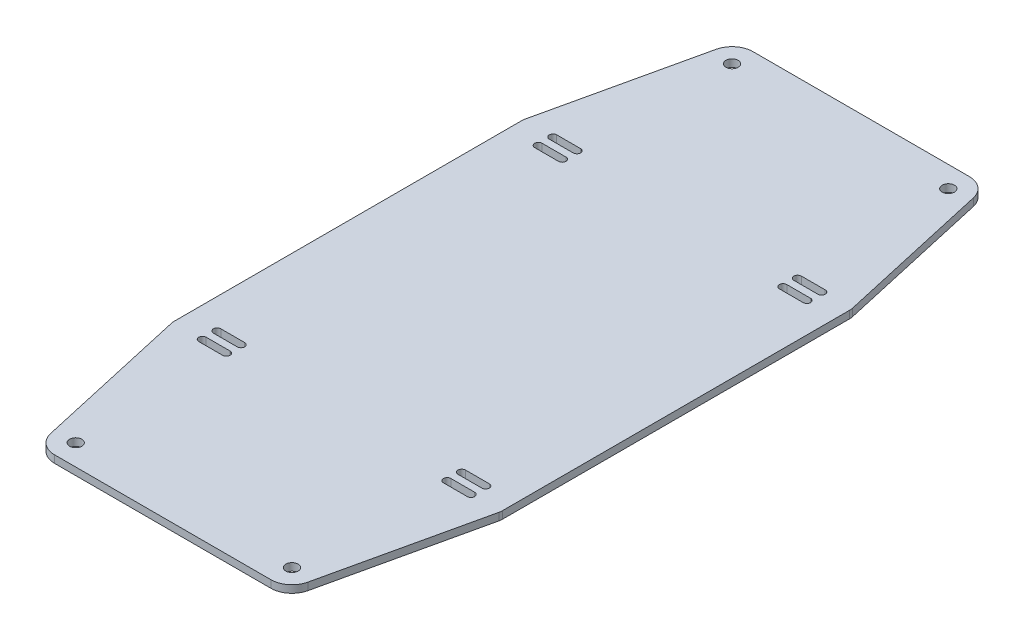
from build123d import *

# Parameters (mm, degrees)
SKETCH1_W               = 283.466794954
SKETCH1_H               = 183.213286571
BOSS_EXTRUDE1_DEPTH     = 3.175
SKETCH2_W               = 283.466794954
SKETCH2_H               = 183.213286571
CUT_EXTRUDE1_DEPTH      = 4.175
SKETCH4_W               = 139.7
SKETCH4_H               = 76.2
BOSS_EXTRUDE2_DEPTH     = 3.175
CUT_EXTRUDE2_DEPTH      = 4.175
CUT_EXTRUDE3_DEPTH      = 1
CUT_EXTRUDE3_DEPTH_BACK = 4.175
FILLET1_R               = 6.35


with BuildPart() as part:
    # Sketch1 → Boss-Extrude1 (new body)
    with BuildSketch(Plane(origin=(0, 0, 0), x_dir=(1, 0, 0), z_dir=(0, 1, 0))):
        with Locations((1.754436397, -4.260774107)):
            Rectangle(SKETCH1_W, SKETCH1_H)
    extrude(amount=BOSS_EXTRUDE1_DEPTH)

    # Sketch2 → Cut-Extrude1 (cut, through all)
    with BuildSketch(Plane(origin=(0, 3.175, 0), x_dir=(1, 0, 0), z_dir=(0, 1, 0))):
        with Locations((1.754436397, -4.260774107)):
            Rectangle(SKETCH2_W, SKETCH2_H)
        Polygon((14.612631792, -92.535731899), (1.912631792, -92.535731899), (1.912631792, -79.835731899), (1.912631792, 78.914268101), (141.612631792, 78.914268101), (141.612631792, -79.835731899), (141.612631792, -92.535731899), (128.912631792, -92.535731899), align=None, mode=Mode.SUBTRACT)
        with BuildLine():
            Line((24.772631792, 63.166268101), (14.612631792, 63.166268101))
            Line((14.612631792, 63.166268101), (14.612631792, 59.991268101))
            Line((14.612631792, 59.991268101), (24.772631792, 59.991268101))
            ThreePointArc((24.772631792, 59.991268101), (26.360131792, 61.578768101), (24.772631792, 63.166268101))
        make_face()
        with BuildLine():
            Line((14.612631792, 59.991268101), (14.612631792, 63.166268101))
            ThreePointArc((14.612631792, 63.166268101), (13.025131792, 61.578768101), (14.612631792, 59.991268101))
        make_face()
        with BuildLine():
            ThreePointArc((14.612631792, 69.389268101), (13.025131792, 67.801768101), (14.612631792, 66.214268101))
            Line((14.612631792, 66.214268101), (24.772631792, 66.214268101))
            ThreePointArc((24.772631792, 66.214268101), (26.360131792, 67.801768101), (24.772631792, 69.389268101))
            Line((24.772631792, 69.389268101), (14.612631792, 69.389268101))
        make_face()
        with BuildLine():
            Line((128.912631792, 63.166268101), (118.752631792, 63.166268101))
            ThreePointArc((118.752631792, 63.166268101), (117.165131792, 61.578768101), (118.752631792, 59.991268101))
            Line((118.752631792, 59.991268101), (128.912631792, 59.991268101))
            Line((128.912631792, 59.991268101), (128.912631792, 63.166268101))
        make_face()
        with BuildLine():
            ThreePointArc((118.752631792, 69.389268101), (117.165131792, 67.801768101), (118.752631792, 66.214268101))
            Line((118.752631792, 66.214268101), (128.912631792, 66.214268101))
            ThreePointArc((128.912631792, 66.214268101), (130.500131792, 67.801768101), (128.912631792, 69.389268101))
            Line((128.912631792, 69.389268101), (118.752631792, 69.389268101))
        make_face()
        with BuildLine():
            ThreePointArc((128.912631792, -83.010731899), (130.500131792, -81.423231899), (128.912631792, -79.835731899))
            Line((128.912631792, -79.835731899), (118.752631792, -79.835731899))
            ThreePointArc((118.752631792, -79.835731899), (117.165131792, -81.423231899), (118.752631792, -83.010731899))
            Line((118.752631792, -83.010731899), (128.912631792, -83.010731899))
        make_face()
        with BuildLine():
            ThreePointArc((128.912631792, -76.787731899), (130.500131792, -75.200231899), (128.912631792, -73.612731899))
            Line((128.912631792, -73.612731899), (128.912631792, -76.787731899))
        make_face()
        with BuildLine():
            Line((128.912631792, -76.787731899), (128.912631792, -73.612731899))
            Line((128.912631792, -73.612731899), (118.752631792, -73.612731899))
            ThreePointArc((118.752631792, -73.612731899), (117.165131792, -75.200231899), (118.752631792, -76.787731899))
            Line((118.752631792, -76.787731899), (128.912631792, -76.787731899))
        make_face()
        with BuildLine():
            ThreePointArc((128.912631792, 59.991268101), (130.500131792, 61.578768101), (128.912631792, 63.166268101))
            Line((128.912631792, 63.166268101), (128.912631792, 59.991268101))
        make_face()
        with BuildLine():
            Line((24.772631792, -79.835731899), (14.612631792, -79.835731899))
            ThreePointArc((14.612631792, -79.835731899), (13.025131792, -81.423231899), (14.612631792, -83.010731899))
            Line((14.612631792, -83.010731899), (24.772631792, -83.010731899))
            ThreePointArc((24.772631792, -83.010731899), (26.360131792, -81.423231899), (24.772631792, -79.835731899))
        make_face()
        with BuildLine():
            Line((24.772631792, -73.612731899), (14.612631792, -73.612731899))
            Line((14.612631792, -73.612731899), (14.612631792, -76.787731899))
            Line((14.612631792, -76.787731899), (24.772631792, -76.787731899))
            ThreePointArc((24.772631792, -76.787731899), (26.360131792, -75.200231899), (24.772631792, -73.612731899))
        make_face()
        with BuildLine():
            Line((14.612631792, -76.787731899), (14.612631792, -73.612731899))
            ThreePointArc((14.612631792, -73.612731899), (13.025131792, -75.200231899), (14.612631792, -76.787731899))
        make_face()
    extrude(amount=-CUT_EXTRUDE1_DEPTH, mode=Mode.SUBTRACT)

    # Sketch4 → Boss-Extrude2 (add)
    with BuildSketch(Plane(origin=(0, 3.175, 0), x_dir=(1, 0, 0), z_dir=(0, 1, 0))):
        with Locations((71.762631792, 117.014268101)):
            Rectangle(SKETCH4_W, SKETCH4_H)
        with Locations((71.762631792, -130.635731899)):
            Rectangle(SKETCH4_W, SKETCH4_H)
    extrude(amount=-BOSS_EXTRUDE2_DEPTH)

    # Sketch3 → Cut-Extrude2 (cut, through all)
    with BuildSketch(Plane(origin=(0, 3.175, 0), x_dir=(1, 0, 0), z_dir=(0, 1, 0))):
        with BuildLine():
            ThreePointArc((28.325131792, 132.889268101), (23.886654161, 134.727745733), (25.725131792, 130.289268101))
            Line((25.725131792, 130.289268101), (25.725131792, 132.889268101))
            Line((25.725131792, 132.889268101), (28.325131792, 132.889268101))
        make_face()
        with BuildLine():
            Line((25.725131792, 132.889268101), (25.725131792, 130.289268101))
            ThreePointArc((25.725131792, 130.289268101), (27.563609423, 131.05079047), (28.325131792, 132.889268101))
            Line((28.325131792, 132.889268101), (25.725131792, 132.889268101))
        make_face()
        with BuildLine():
            ThreePointArc((28.325131792, 132.889268101), (23.886654161, 134.727745733), (25.725131792, 130.289268101))
            Line((25.725131792, 130.289268101), (25.725131792, 132.889268101))
            Line((25.725131792, 132.889268101), (28.325131792, 132.889268101))
        make_face()
        with BuildLine():
            Line((25.725131792, 132.889268101), (25.725131792, 130.289268101))
            ThreePointArc((25.725131792, 130.289268101), (27.563609423, 131.05079047), (28.325131792, 132.889268101))
            Line((28.325131792, 132.889268101), (25.725131792, 132.889268101))
        make_face()
        with BuildLine():
            ThreePointArc((115.200131792, 132.889268101), (115.961654161, 131.05079047), (117.800131792, 130.289268101))
            Line((117.800131792, 130.289268101), (117.800131792, 132.889268101))
            Line((117.800131792, 132.889268101), (115.200131792, 132.889268101))
        make_face()
        with BuildLine():
            Line((117.800131792, 132.889268101), (117.800131792, 130.289268101))
            ThreePointArc((117.800131792, 130.289268101), (119.638609423, 131.05079047), (120.400131792, 132.889268101))
            ThreePointArc((120.400131792, 132.889268101), (117.800131792, 135.489268101), (115.200131792, 132.889268101))
            Line((115.200131792, 132.889268101), (117.800131792, 132.889268101))
        make_face()
        with BuildLine():
            ThreePointArc((115.200131792, 132.889268101), (115.961654161, 131.05079047), (117.800131792, 130.289268101))
            Line((117.800131792, 130.289268101), (117.800131792, 132.889268101))
            Line((117.800131792, 132.889268101), (115.200131792, 132.889268101))
        make_face()
        with BuildLine():
            Line((117.800131792, 132.889268101), (117.800131792, 130.289268101))
            ThreePointArc((117.800131792, 130.289268101), (119.638609423, 131.05079047), (120.400131792, 132.889268101))
            ThreePointArc((120.400131792, 132.889268101), (117.800131792, 135.489268101), (115.200131792, 132.889268101))
            Line((115.200131792, 132.889268101), (117.800131792, 132.889268101))
        make_face()
        with BuildLine():
            ThreePointArc((120.400131792, -146.510731899), (119.638609423, -144.672254267), (117.800131792, -143.910731899))
            Line((117.800131792, -143.910731899), (117.800131792, -146.510731899))
            Line((117.800131792, -146.510731899), (115.200131792, -146.510731899))
            ThreePointArc((115.200131792, -146.510731899), (117.800131792, -149.110731899), (120.400131792, -146.510731899))
        make_face()
        with BuildLine():
            Line((117.800131792, -146.510731899), (117.800131792, -143.910731899))
            ThreePointArc((117.800131792, -143.910731899), (115.961654161, -144.672254267), (115.200131792, -146.510731899))
            Line((115.200131792, -146.510731899), (117.800131792, -146.510731899))
        make_face()
        with BuildLine():
            ThreePointArc((120.400131792, -146.510731899), (119.638609423, -144.672254267), (117.800131792, -143.910731899))
            Line((117.800131792, -143.910731899), (117.800131792, -146.510731899))
            Line((117.800131792, -146.510731899), (115.200131792, -146.510731899))
            ThreePointArc((115.200131792, -146.510731899), (117.800131792, -149.110731899), (120.400131792, -146.510731899))
        make_face()
        with BuildLine():
            Line((117.800131792, -146.510731899), (117.800131792, -143.910731899))
            ThreePointArc((117.800131792, -143.910731899), (115.961654161, -144.672254267), (115.200131792, -146.510731899))
            Line((115.200131792, -146.510731899), (117.800131792, -146.510731899))
        make_face()
        with BuildLine():
            ThreePointArc((28.325131792, -146.510731899), (27.563609423, -144.672254267), (25.725131792, -143.910731899))
            Line((25.725131792, -143.910731899), (25.725131792, -146.510731899))
            Line((25.725131792, -146.510731899), (28.325131792, -146.510731899))
        make_face()
        with BuildLine():
            Line((25.725131792, -146.510731899), (25.725131792, -143.910731899))
            ThreePointArc((25.725131792, -143.910731899), (23.886654161, -148.34920953), (28.325131792, -146.510731899))
            Line((28.325131792, -146.510731899), (25.725131792, -146.510731899))
        make_face()
        with BuildLine():
            ThreePointArc((28.325131792, -146.510731899), (27.563609423, -144.672254267), (25.725131792, -143.910731899))
            Line((25.725131792, -143.910731899), (25.725131792, -146.510731899))
            Line((25.725131792, -146.510731899), (28.325131792, -146.510731899))
        make_face()
        with BuildLine():
            Line((25.725131792, -146.510731899), (25.725131792, -143.910731899))
            ThreePointArc((25.725131792, -143.910731899), (23.886654161, -148.34920953), (28.325131792, -146.510731899))
            Line((28.325131792, -146.510731899), (25.725131792, -146.510731899))
        make_face()
    extrude(amount=-CUT_EXTRUDE2_DEPTH, mode=Mode.SUBTRACT)

    # Sketch5 → Cut-Extrude3 (cut, two sides)
    with BuildSketch(Plane(origin=(0, 3.175, 0), x_dir=(1, 0, 0), z_dir=(0, 1, 0))) as cut_extrude3_sk:
        with BuildLine():
            Line((1.912631792, 67.801768101), (16.993258915, 134.853166283))
            ThreePointArc((16.993258915, 134.853166283), (20.133816594, 139.877808318), (25.725131792, 141.839268101))
            Line((25.725131792, 141.839268101), (117.800131792, 141.839268101))
            ThreePointArc((117.800131792, 141.839268101), (123.39144699, 139.877808318), (126.532004669, 134.853166283))
            Line((126.532004669, 134.853166283), (141.612631792, 67.801768101))
            Line((141.612631792, 67.801768101), (141.612631792, 155.114268101))
            Line((141.612631792, 155.114268101), (1.912631792, 155.114268101))
            Line((1.912631792, 155.114268101), (1.912631792, 67.801768101))
        make_face()
        with BuildLine():
            Line((16.993258915, -148.47463008), (1.912631792, -81.423231899))
            Line((1.912631792, -81.423231899), (1.912631792, -168.735731899))
            Line((1.912631792, -168.735731899), (141.612631792, -168.735731899))
            Line((141.612631792, -168.735731899), (141.612631792, -81.423231899))
            Line((141.612631792, -81.423231899), (126.532004669, -148.47463008))
            ThreePointArc((126.532004669, -148.47463008), (123.39144699, -153.499272115), (117.800131792, -155.460731899))
            Line((117.800131792, -155.460731899), (25.725131792, -155.460731899))
            ThreePointArc((25.725131792, -155.460731899), (20.133816594, -153.499272115), (16.993258915, -148.47463008))
        make_face()
    extrude(amount=CUT_EXTRUDE3_DEPTH, mode=Mode.SUBTRACT)
    extrude(cut_extrude3_sk.sketch, amount=-CUT_EXTRUDE3_DEPTH_BACK, mode=Mode.SUBTRACT)

    # Fillet1
    fillet1_edges = [part.edges().sort_by_distance(p)[0] for p in [
        (1.912631792, 1.5875, -67.801768101),
        (141.612631792, 1.5875, -67.801768101),
        (141.612631792, 1.5875, 81.423231899),
        (1.912631792, 1.5875, 81.423231899),
    ]]
    fillet(fillet1_edges, radius=FILLET1_R)


solid = part.part
